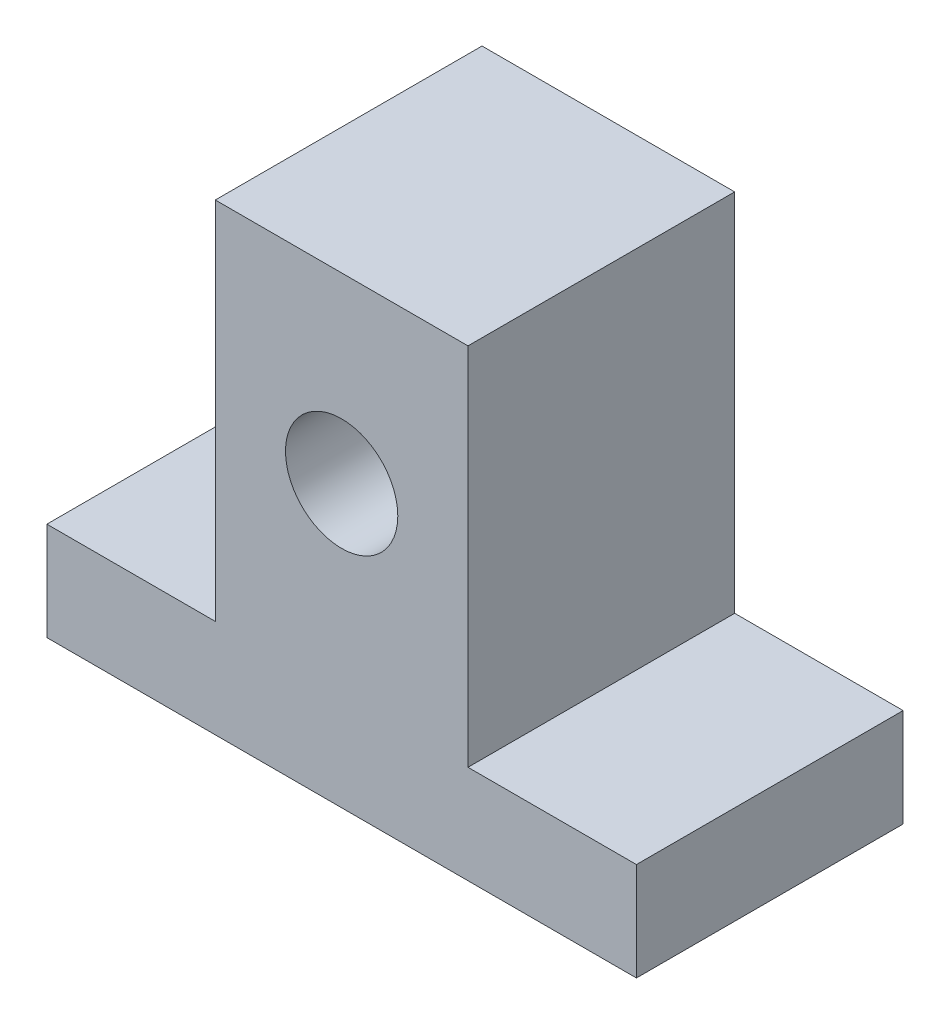
from build123d import *

# Parameters (mm, degrees)
SKETCH2_R           = 4
BOSS_EXTRUDE1_DEPTH = 19


with BuildPart() as part:
    # Sketch2 → Boss-Extrude1 (new body)
    with BuildSketch(Plane.XY):
        Polygon((-21, 0), (21, 0), (21, 7), (9, 7), (9, 33), (-9, 33), (-9, 7), (-21, 7), align=None)
        with Locations((0, 20)):
            Circle(SKETCH2_R, mode=Mode.SUBTRACT)
    extrude(amount=BOSS_EXTRUDE1_DEPTH)


solid = part.part
